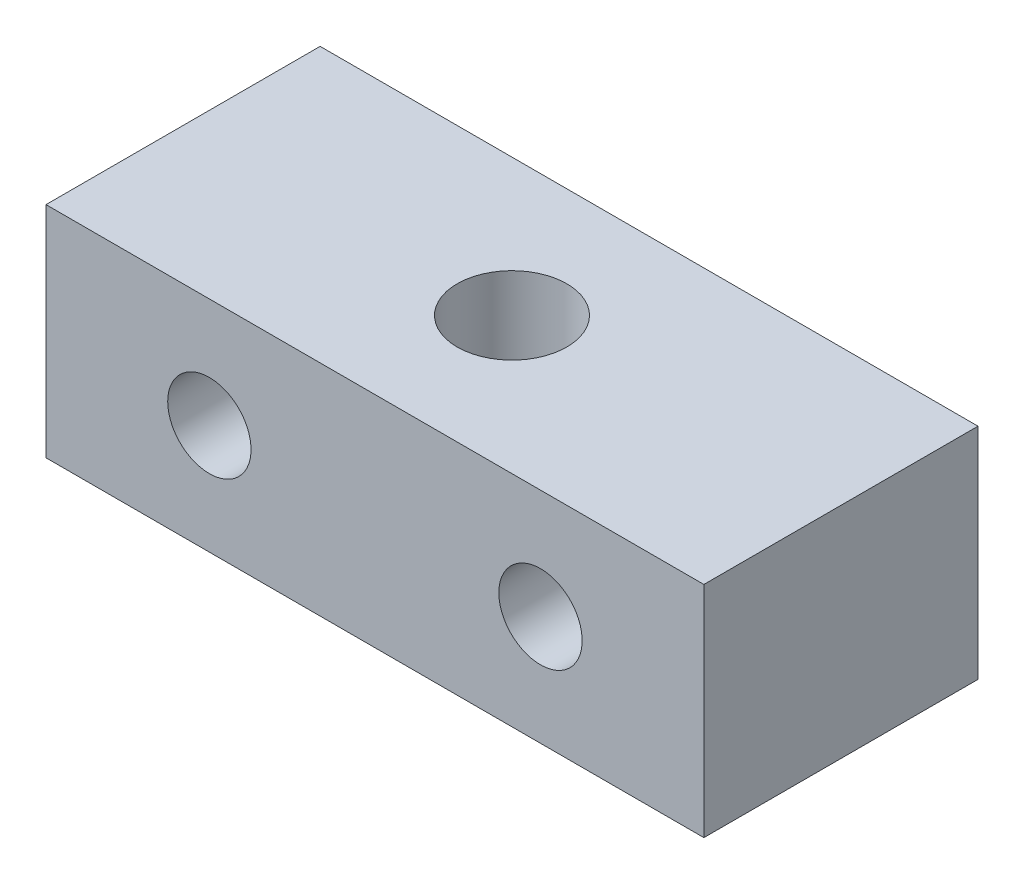
from build123d import *

# Parameters (mm, degrees)
SKETCH1_W           = 38.1
SKETCH1_H           = 15.875
BOSS_EXTRUDE1_DEPTH = 12.7
SKETCH2_R           = 2.413
CUT_EXTRUDE1_DEPTH  = 16.875
SKETCH3_R           = 3.175
CUT_EXTRUDE2_DEPTH  = 13.7


with BuildPart() as part:
    # Sketch1 → Boss-Extrude1 (new body)
    with BuildSketch(Plane(origin=(0, 0, 0), x_dir=(1, 0, 0), z_dir=(0, 1, 0))):
        Rectangle(SKETCH1_W, SKETCH1_H)
    extrude(amount=BOSS_EXTRUDE1_DEPTH)

    # Sketch2 → Cut-Extrude1 (cut, through all)
    with BuildSketch(Plane(origin=(0, 0, -7.9375), x_dir=(-1, 0, 0), z_dir=(0, 0, -1))):
        with Locations((-9.5885, 6.35)):
            Circle(SKETCH2_R)
        with Locations((9.5885, 6.35)):
            Circle(SKETCH2_R)
    extrude(amount=-CUT_EXTRUDE1_DEPTH, mode=Mode.SUBTRACT)

    # Sketch3 → Cut-Extrude2 (cut, through all)
    with BuildSketch(Plane(origin=(0, 12.7, 0), x_dir=(1, 0, 0), z_dir=(0, 1, 0))):
        Circle(SKETCH3_R)
    extrude(amount=-CUT_EXTRUDE2_DEPTH, mode=Mode.SUBTRACT)


solid = part.part
